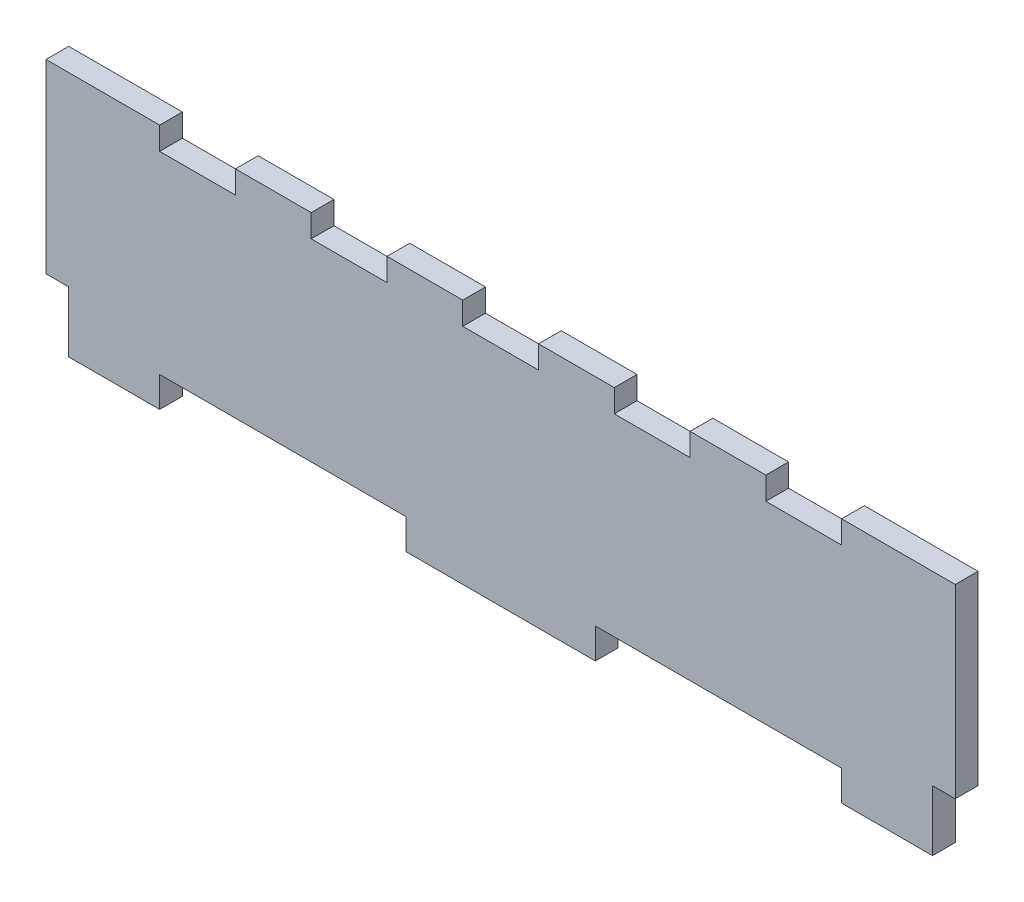
from build123d import *

# Parameters (mm, degrees)
SKETCH1_W           = 240
SKETCH1_H           = 65
BOSS_EXTRUDE1_DEPTH = 3
SKETCH2_W           = 6
SKETCH2_H           = 16
SKETCH2_W_2         = 65
SKETCH2_H_2         = 8
CUT_EXTRUDE1_DEPTH  = 6
SKETCH3_W           = 20
SKETCH3_H           = 6
CUT_EXTRUDE2_DEPTH  = 6


with BuildPart() as part:
    # Sketch1 → Boss-Extrude1 (new body, symmetric)
    with BuildSketch(Plane.XY):
        Rectangle(SKETCH1_W, SKETCH1_H)
    extrude(amount=BOSS_EXTRUDE1_DEPTH, both=True)

    # Sketch2 → Cut-Extrude1 (cut)
    with BuildSketch(Plane.XY.offset(3)):
        with Locations((-117, -24.5)):
            Rectangle(SKETCH2_W, SKETCH2_H)
        with Locations((-57.5, -28.5)):
            Rectangle(SKETCH2_W_2, SKETCH2_H_2)
        with Locations((57.5, -28.5)):
            Rectangle(SKETCH2_W_2, SKETCH2_H_2)
        with Locations((117, -24.5)):
            Rectangle(SKETCH2_W, SKETCH2_H)
    extrude(amount=-CUT_EXTRUDE1_DEPTH, mode=Mode.SUBTRACT)

    # Sketch3 → Cut-Extrude2 (cut)
    with BuildSketch(Plane.XY.offset(3)):
        with Locations((-80, 29.5)):
            Rectangle(SKETCH3_W, SKETCH3_H)
        with Locations((-40, 29.5)):
            Rectangle(SKETCH3_W, SKETCH3_H)
        with Locations((0, 29.5)):
            Rectangle(SKETCH3_W, SKETCH3_H)
        with Locations((40, 29.5)):
            Rectangle(SKETCH3_W, SKETCH3_H)
        with Locations((80, 29.5)):
            Rectangle(SKETCH3_W, SKETCH3_H)
    extrude(amount=-CUT_EXTRUDE2_DEPTH, mode=Mode.SUBTRACT)


solid = part.part
